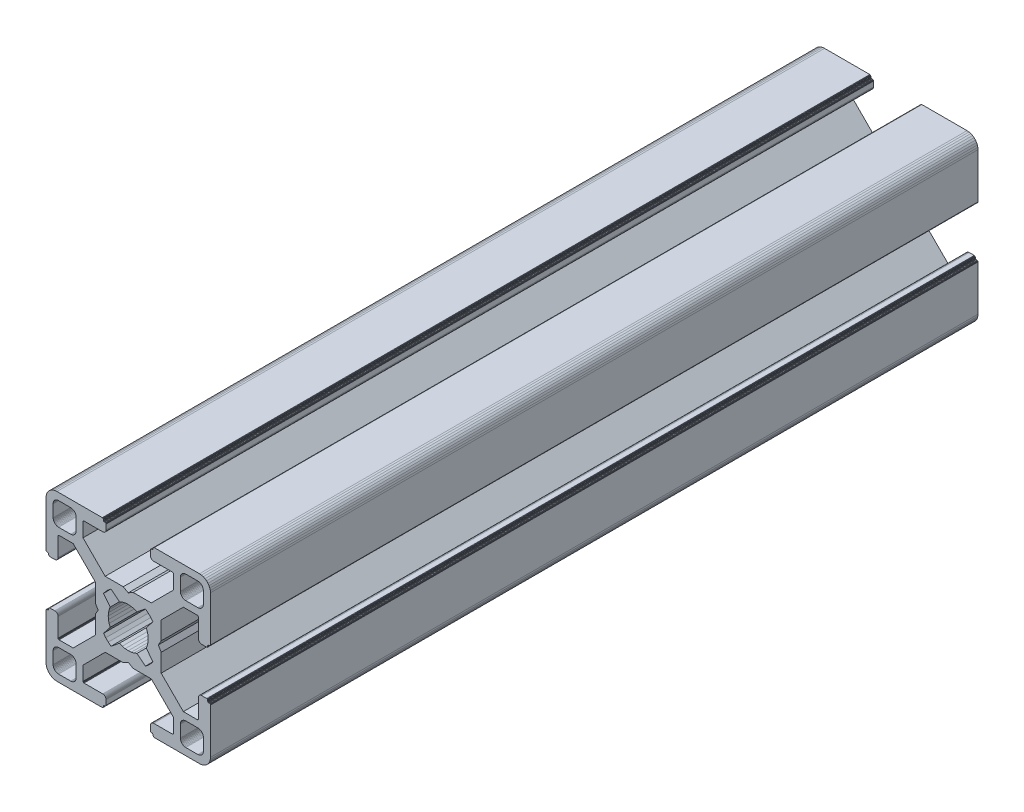
from build123d import *

# Parameters (mm, degrees)
BOSS_EXTRUDE1_DEPTH = 140


with BuildPart() as part:
    # Sketch1 → Boss-Extrude1 (new body)
    with BuildSketch(Plane.XY):
        Polygon((28.34729664, 29.969613999), (28.000000864, 29.999999329), (19.750000909, 29.999999329), (19.715268165, 29.996961355), (19.681595266, 29.987938702), (19.649999216, 29.973205179), (19.621443003, 29.953207821), (19.596790895, 29.928557575), (19.576793537, 29.899999499), (19.562061876, 29.868405312), (19.55303736, 29.834728688), (19.549999386, 29.799999669), (19.549999386, 29.699999839), (19.546961412, 29.665268958), (19.537936896, 29.631596059), (19.523203373, 29.599998146), (19.503207877, 29.571441934), (19.478557631, 29.546789825), (19.449999556, 29.526794329), (19.418403506, 29.512060806), (19.384728745, 29.503038153), (19.349999726, 29.500000179), (19.249999896, 29.500000179), (19.215267517, 29.496958527), (19.181592755, 29.487935874), (19.149996706, 29.47320235), (19.12143863, 29.453206855), (19.096788384, 29.428554746), (19.076791026, 29.399996671), (19.062057503, 29.368402484), (19.05303485, 29.334725859), (19.049996876, 29.299998703), (19.049996876, 28.39999837), (19.059110798, 28.29580945), (19.08618062, 28.194785165), (19.13038119, 28.099997016), (19.190369539, 28.014324653), (19.264324002, 27.94037019), (19.349996366, 27.88038184), (19.444784515, 27.836181271), (19.545806937, 27.809111449), (19.650010894, 27.799984574), (23.050010706, 27.799984574), (23.084741588, 27.7969466), (23.118414487, 27.787923946), (23.150012399, 27.773190423), (23.178568612, 27.753193065), (23.203220721, 27.728542819), (23.223218079, 27.699984744), (23.237949739, 27.668386831), (23.246974255, 27.634713932), (23.25001142, 27.59998608), (23.25001142, 25.049987618), (19.204474482, 20.999982084), (15.900007876, 20.999982084), (15.000008474, 20.48483404), (14.10000814, 20.999982084), (10.795543398, 20.999982084), (7.997342887, 23.801274731), (6.750011387, 25.049984589), (6.750011387, 27.599983051), (6.753049362, 27.634713932), (6.762072946, 27.668386831), (6.776805538, 27.699984744), (6.796801965, 27.728542819), (6.821454073, 27.753193065), (6.850011218, 27.773190423), (6.881607267, 27.787923946), (6.915282029, 27.7969466), (6.950011048, 27.799984574), (10.350011791, 27.799984574), (10.45420071, 27.809098497), (10.555223133, 27.836168318), (10.650011282, 27.880368888), (10.735683645, 27.940357238), (10.809638108, 28.014311701), (10.869626458, 28.099984064), (10.913827027, 28.194772213), (10.940895918, 28.295796498), (10.950010772, 28.399985417), (10.950010772, 29.299985751), (10.946974575, 29.334739239), (10.93795065, 29.368415522), (10.923215933, 29.400009153), (10.903218427, 29.428566473), (10.878566319, 29.45321765), (10.849999264, 29.473204166), (10.818403214, 29.487937689), (10.784728453, 29.496960342), (10.749999434, 29.500000179), (10.649999604, 29.500000179), (10.615270585, 29.503038153), (10.581595823, 29.512060806), (10.549999774, 29.526794329), (10.521441698, 29.546789825), (10.496791452, 29.571441934), (10.476795025, 29.599998146), (10.462061502, 29.631596059), (10.453037918, 29.665268958), (10.449999943, 29.699999839), (10.449999943, 29.799999669), (10.446961969, 29.834728688), (10.437938385, 29.868405312), (10.423205793, 29.899999499), (10.403208435, 29.928557575), (10.378557257, 29.953207821), (10.350000113, 29.973205179), (10.318404064, 29.987938702), (10.284729302, 29.996961355), (10.250000283, 29.999999329), (1.999999397, 29.999999329), (1.652702689, 29.969613999), (1.315958682, 29.879383743), (0.999999233, 29.732050374), (0.714424066, 29.532089829), (0.467910431, 29.285576195), (0.267948955, 28.999999166), (0.120614655, 28.684040532), (0.030384399, 28.34729664), (0, 28.000000864), (0, 19.750000909), (0.003037974, 19.715268165), (0.012061559, 19.681595266), (0.026795082, 19.649999216), (0.046790577, 19.621441141), (0.071442686, 19.596789032), (0.09999983, 19.576793537), (0.13159588, 19.562060013), (0.165270641, 19.55303736), (0.19999966, 19.549999386), (0.299999461, 19.549999386), (0.334728509, 19.546959549), (0.368403242, 19.537936896), (0.399999321, 19.523203373), (0.428556465, 19.503207877), (0.453208573, 19.478555769), (0.473204069, 19.449997693), (0.487937592, 19.418403506), (0.496961176, 19.384728745), (0.499999151, 19.349999726), (0.499999151, 19.249998033), (0.503038056, 19.215269014), (0.512060709, 19.181594253), (0.526794232, 19.150000066), (0.546790194, 19.121441524), (0.571441837, 19.096789882), (0.60000029, 19.076794925), (0.631595686, 19.062061999), (0.665270619, 19.053039982), (0.700000626, 19.050000801), (1.60000096, 19.050000801), (1.704189879, 19.059116587), (1.805213233, 19.086186409), (1.90000045, 19.130385115), (1.985673745, 19.190375328), (2.059627277, 19.264327928), (2.119616325, 19.350002154), (2.163816196, 19.444788441), (2.190886018, 19.545812726), (2.200000872, 19.650001645), (2.200000872, 23.050001457), (2.203039777, 23.084732338), (2.212062431, 23.118405237), (2.226795954, 23.15000315), (2.246792381, 23.178559362), (2.271443558, 23.203211471), (2.300000702, 23.223206967), (2.331596752, 23.23794049), (2.365271513, 23.246965006), (2.400001464, 23.250001117), (4.950000857, 23.250001117), (7.997332093, 20.202670812), (8.995535423, 19.204467788), (8.995535423, 15.900001182), (9.515148227, 15.00000178), (8.995535423, 14.100002378), (8.995535423, 10.795536704), (4.950000857, 6.750002138), (2.400001464, 6.750002138), (2.365271513, 6.753040112), (2.331596752, 6.762063697), (2.300000702, 6.77679722), (2.271443558, 6.796793647), (2.246792381, 6.821444824), (2.226795954, 6.850001968), (2.212062431, 6.881598018), (2.203039777, 6.915272779), (2.200000872, 6.950002729), (2.200000872, 10.350002542), (2.190896812, 10.454174265), (2.16382699, 10.555197618), (2.119627119, 10.649984836), (2.059638071, 10.735658131), (1.985684539, 10.809611663), (1.900011244, 10.869600944), (1.805224027, 10.913800582), (1.704200673, 10.940870404), (1.600011754, 10.949986189), (0.70001142, 10.949986189), (0.665281355, 10.946948596), (0.631606253, 10.937926283), (0.600010578, 10.923193954), (0.571451747, 10.903199537), (0.546799638, 10.87854836), (0.526794232, 10.850000195), (0.512060709, 10.818404146), (0.503038056, 10.784730315), (0.499999151, 10.750000365), (0.499999151, 10.650000535), (0.496961176, 10.615270585), (0.487937592, 10.581596754), (0.473204069, 10.550000705), (0.453208573, 10.521443561), (0.428556465, 10.496791452), (0.399999321, 10.476795956), (0.368403242, 10.462062433), (0.334728509, 10.453038849), (0.299999461, 10.449999943), (0.19999966, 10.449999943), (0.165270641, 10.446961969), (0.13159588, 10.437939316), (0.09999983, 10.423205793), (0.071442686, 10.403209366), (0.046790577, 10.378558189), (0.026795082, 10.350000113), (0.012061559, 10.318404064), (0.003037974, 10.284729302), (0, 10.250000283), (0, 1.999999397), (0.030384399, 1.652702689), (0.120614655, 1.315958682), (0.267948955, 0.999999233), (0.467910431, 0.714424066), (0.714424066, 0.467910431), (0.999999233, 0.267948955), (1.315958682, 0.120614655), (1.652702689, 0.030384399), (1.999999397, 0), (10.250000283, 0), (10.284729302, 0.003037974), (10.318404064, 0.012061559), (10.350000113, 0.026795082), (10.378557257, 0.046790577), (10.403208435, 0.071442686), (10.423205793, 0.09999983), (10.437938385, 0.13159588), (10.446961969, 0.165270641), (10.449999943, 0.19999966), (10.449999943, 0.300000422), (10.453037918, 0.334729441), (10.462061502, 0.368404202), (10.476795025, 0.400000252), (10.496791452, 0.428557396), (10.521441698, 0.453208573), (10.549999774, 0.473205), (10.581595823, 0.487938523), (10.615270585, 0.496961176), (10.649999604, 0.500000082), (10.749999434, 0.500000082), (10.784728453, 0.503038056), (10.818403214, 0.512060709), (10.849999264, 0.526794232), (10.878547894, 0.546800104), (10.903198606, 0.571451747), (10.923194493, 0.6000102), (10.93792742, 0.631606528), (10.946949437, 0.66528146), (10.950010772, 0.699984975), (10.950010772, 1.599985308), (10.940895918, 1.704174228), (10.913827027, 1.805197581), (10.869626458, 1.89998573), (10.809638108, 1.985658094), (10.735683645, 2.059612557), (10.650011282, 2.119600674), (10.555223133, 2.163801476), (10.45420071, 2.190870367), (10.350011791, 2.199985221), (6.950011048, 2.199985221), (6.915282029, 2.203024126), (6.881607267, 2.212046779), (6.850011218, 2.226780302), (6.821454073, 2.246776729), (6.796801965, 2.271427907), (6.776805538, 2.299985982), (6.762072946, 2.331582032), (6.753049362, 2.365256793), (6.750011387, 2.399985812), (6.750011387, 4.949985206), (9.787457566, 7.990785077), (10.795545277, 8.999985833), (14.100010019, 8.999985833), (15.000010353, 9.515133877), (15.900009756, 8.999985833), (19.204476361, 8.999985833), (20.21256413, 7.990786065), (23.25001142, 4.949988235), (23.25001142, 2.399988841), (23.246974255, 2.365256793), (23.237949739, 2.331582032), (23.223218079, 2.299985982), (23.203220721, 2.271427907), (23.178568612, 2.246776729), (23.150012399, 2.226780302), (23.118414487, 2.212046779), (23.084741588, 2.203024126), (23.050010706, 2.199985221), (19.650010894, 2.199985221), (19.545806937, 2.190883319), (19.444784515, 2.163814428), (19.349996366, 2.119613626), (19.264324002, 2.059625509), (19.190369539, 1.985671046), (19.13038119, 1.899998682), (19.08618062, 1.805210533), (19.059110798, 1.70418718), (19.049996876, 1.599998261), (19.049996876, 0.699997927), (19.053035506, 0.665268966), (19.062058795, 0.631594374), (19.076792915, 0.599998603), (19.096790813, 0.571440905), (19.121441524, 0.546790194), (19.149999978, 0.526794306), (19.181596306, 0.51206138), (19.215271238, 0.503039363), (19.249999896, 0.500000082), (19.349999726, 0.500000082), (19.384728745, 0.496961176), (19.418403506, 0.487938523), (19.449999556, 0.473205), (19.478557631, 0.453208573), (19.503207877, 0.428557396), (19.523203373, 0.400000252), (19.537936896, 0.368404202), (19.546961412, 0.334729441), (19.549999386, 0.300000422), (19.549999386, 0.19999966), (19.55303736, 0.165270641), (19.562061876, 0.13159588), (19.576793537, 0.09999983), (19.596789964, 0.071441755), (19.621442072, 0.046789646), (19.649998285, 0.02679415), (19.681594335, 0.012060627), (19.715267234, 0.003037043), (19.750000909, 0), (28.000000864, 0), (28.34729664, 0.030384399), (28.684040532, 0.120614655), (28.999999166, 0.267948955), (29.285576195, 0.467910431), (29.532089829, 0.714424066), (29.732050374, 0.999999233), (29.879383743, 1.315958682), (29.969613999, 1.652702689), (29.999999329, 1.999999397), (29.999999329, 10.250000283), (29.996974806, 10.284715361), (29.987951516, 10.318389952), (29.973217396, 10.349985723), (29.953219499, 10.378543421), (29.928568787, 10.403194133), (29.899999499, 10.423205793), (29.868405312, 10.437939316), (29.834728688, 10.446961969), (29.799999669, 10.449999943), (29.699999839, 10.449999943), (29.664909937, 10.453400043), (29.631233313, 10.462423628), (29.599637263, 10.477157151), (29.57108105, 10.497152646), (29.546427079, 10.521804755), (29.526433446, 10.550361899), (29.511699923, 10.581957949), (29.502675407, 10.615631779), (29.499637433, 10.650361729), (29.499637433, 10.750361559), (29.49697202, 10.784715548), (29.487949367, 10.818389378), (29.473215844, 10.849985428), (29.453220348, 10.878542572), (29.428568239, 10.90319468), (29.400010164, 10.923190176), (29.368415977, 10.937923699), (29.334741215, 10.946947284), (29.300012197, 10.949986189), (28.400011863, 10.949986189), (28.29581215, 10.9408876), (28.194787865, 10.913817778), (28.099999716, 10.86961814), (28.014327352, 10.809628859), (27.940374752, 10.735675327), (27.880384539, 10.650002032), (27.836185833, 10.555214814), (27.809114148, 10.454191461), (27.800000225, 10.350002542), (27.800000225, 6.950002729), (27.796962251, 6.915272779), (27.787939598, 6.881598018), (27.773206075, 6.850001968), (27.753208716, 6.821444824), (27.728558471, 6.796793647), (27.700000395, 6.77679722), (27.668404345, 6.762063697), (27.634729584, 6.753040112), (27.599998702, 6.750002138), (25.05000024, 6.750002138), (23.809199132, 7.99080223), (21.004464477, 10.795534588), (21.004464477, 14.100000262), (20.484851673, 14.999999665), (21.004464477, 15.899999067), (21.004464477, 19.204465672), (25.05000024, 23.250001117), (27.599998702, 23.250001117), (27.634729584, 23.246965006), (27.668404345, 23.23794049), (27.700000395, 23.223206967), (27.728558471, 23.203211471), (27.753208716, 23.178559362), (27.773206075, 23.15000315), (27.787939598, 23.118405237), (27.796962251, 23.084732338), (27.800000225, 23.050001457), (27.800000225, 19.650001645), (27.809114148, 19.545812726), (27.836185833, 19.444788441), (27.880384539, 19.350002154), (27.940370508, 19.264323684), (28.014323108, 19.190371084), (28.099995472, 19.130380872), (28.194783621, 19.086182165), (28.295807906, 19.059112343), (28.400001069, 19.050000801), (29.300001402, 19.050000801), (29.334730421, 19.053040638), (29.368405183, 19.062063291), (29.39999937, 19.076796814), (29.42819671, 19.097149726), (29.452848353, 19.1218023), (29.472843309, 19.150360754), (29.487576235, 19.181955219), (29.496598252, 19.215630151), (29.499637433, 19.250359227), (29.499637433, 19.35036092), (29.502675407, 19.385089939), (29.511699923, 19.4187647), (29.526433446, 19.450358887), (29.546427079, 19.478916963), (29.57108105, 19.503569071), (29.599637263, 19.523564567), (29.631233313, 19.53829809), (29.664909937, 19.547320743), (29.699999839, 19.549999386), (29.799999669, 19.549999386), (29.834728688, 19.55303736), (29.868405312, 19.562060013), (29.899999499, 19.576793537), (29.928557575, 19.596789032), (29.953207821, 19.621441141), (29.973205179, 19.649999216), (29.987938702, 19.681595266), (29.996961355, 19.715268165), (29.999999329, 19.750000909), (29.999999329, 28.000000864), (29.969613999, 28.34729664), (29.879383743, 28.684040532), (29.732050374, 28.999999166), (29.532089829, 29.285576195), (29.285576195, 29.532089829), (28.999999166, 29.732050374), (28.684040532, 29.879383743), align=None)
        Polygon((1.299998723, 25.499999523), (1.299998723, 27.699999511), (1.312309876, 27.856435627), (1.348942518, 28.009016067), (1.408992335, 28.153989464), (1.490981318, 28.287785128), (1.592892222, 28.407108039), (1.71221327, 28.50901708), (1.846008119, 28.591006994), (1.9909814, 28.651056811), (2.143563703, 28.687689453), (2.299998887, 28.699999675), (4.499998875, 28.699999675), (4.656434059, 28.687689453), (4.809016362, 28.651056811), (4.953989759, 28.591006994), (5.087784491, 28.50901708), (5.207106471, 28.407108039), (5.309016444, 28.287785128), (5.391005427, 28.153989464), (5.451056175, 28.009016067), (5.487687886, 27.856435627), (5.499999039, 27.699999511), (5.499999039, 25.499999523), (5.487687886, 25.34356527), (5.451056175, 25.190982968), (5.391005427, 25.04600957), (5.309016444, 24.912213907), (5.207106471, 24.792892858), (5.087784491, 24.690981954), (4.953989759, 24.60899204), (4.809016362, 24.548944086), (4.656434059, 24.512309581), (4.499998875, 24.499999359), (2.299998887, 24.499999359), (2.143563703, 24.512309581), (1.9909814, 24.548944086), (1.846008119, 24.60899204), (1.71221327, 24.690981954), (1.592892222, 24.792892858), (1.490981318, 24.912213907), (1.408992335, 25.04600957), (1.348942518, 25.190982968), (1.312309876, 25.34356527), align=None, mode=Mode.SUBTRACT)
        Polygon((25.34356527, 28.687689453), (25.499999523, 28.699999675), (27.699999511, 28.699999675), (27.856435627, 28.687689453), (28.009017929, 28.651056811), (28.153991327, 28.591006994), (28.28778699, 28.50901708), (28.407108039, 28.407108039), (28.50901708, 28.287785128), (28.591006994, 28.153989464), (28.651056811, 28.009016067), (28.687689453, 27.856435627), (28.700001538, 27.699999511), (28.700001538, 25.499999523), (28.687689453, 25.34356527), (28.651056811, 25.190982968), (28.591006994, 25.04600957), (28.50901708, 24.912213907), (28.407108039, 24.792892858), (28.28778699, 24.690981954), (28.153991327, 24.60899204), (28.009017929, 24.548944086), (27.856435627, 24.512309581), (27.699999511, 24.499999359), (25.499999523, 24.499999359), (25.34356527, 24.512309581), (25.190982968, 24.548944086), (25.04600957, 24.60899204), (24.912215769, 24.690981954), (24.792892858, 24.792892858), (24.690981954, 24.912213907), (24.608993903, 25.04600957), (24.548944086, 25.190982968), (24.512311444, 25.34356527), (24.500001222, 25.499999523), (24.500001222, 27.699999511), (24.512311444, 27.856435627), (24.548944086, 28.009016067), (24.608993903, 28.153989464), (24.690981954, 28.287785128), (24.792892858, 28.407108039), (24.912215769, 28.50901708), (25.04600957, 28.591006994), (25.190982968, 28.651056811), align=None, mode=Mode.SUBTRACT)
        Polygon((14.999999665, 18.649999052), (15.550030395, 18.608318642), (16.087498516, 18.484227359), (16.600128263, 18.280562013), (18.13592948, 19.518401474), (18.644984812, 19.11874488), (19.103571773, 18.662061542), (19.505336881, 18.154669553), (18.280562013, 16.600130126), (18.484227359, 16.087498516), (18.608318642, 15.550030395), (18.649999052, 14.999999665), (18.608318642, 14.449968934), (18.484227359, 13.912500814), (18.280562013, 13.399870135), (19.505336881, 11.845329776), (19.103571773, 11.337937787), (18.644984812, 10.881252587), (18.13592948, 10.481598787), (16.600128263, 11.719437316), (16.087498516, 11.515771039), (15.550030395, 11.391680688), (14.999999665, 11.349999346), (14.449968934, 11.391680688), (13.912500814, 11.515771039), (13.399870135, 11.719437316), (11.864069849, 10.481598787), (11.355013587, 10.881252587), (10.896427557, 11.337937787), (10.494662449, 11.845329776), (11.719438247, 13.399870135), (11.515771039, 13.912500814), (11.391680688, 14.449968934), (11.349999346, 14.999999665), (11.391680688, 15.550030395), (11.515771039, 16.087498516), (11.719438247, 16.600130126), (10.494662449, 18.154669553), (10.896427557, 18.662061542), (11.355013587, 19.11874488), (11.864069849, 19.518401474), (13.399870135, 18.280562013), (13.912500814, 18.484227359), (14.449968934, 18.608318642), align=None, mode=Mode.SUBTRACT)
        Polygon((4.499998875, 1.299999771), (2.299998887, 1.299999771), (2.143563703, 1.312310807), (1.9909814, 1.348942518), (1.846008119, 1.408992335), (1.71221327, 1.490982249), (1.592892222, 1.592892222), (1.490981318, 1.712214202), (1.408992335, 1.846008934), (1.348942518, 1.990982331), (1.312309876, 2.143564634), (1.299998723, 2.299998887), (1.299998723, 4.499999806), (1.312309876, 4.656434059), (1.348942518, 4.809017293), (1.408992335, 4.95399069), (1.490981318, 5.087785423), (1.592892222, 5.207106471), (1.71221327, 5.309017375), (1.846008119, 5.391006358), (1.9909814, 5.451056175), (2.143563703, 5.487688817), (2.299998887, 5.49999997), (4.499998875, 5.49999997), (4.656434059, 5.487688817), (4.809016362, 5.451056175), (4.953989759, 5.391006358), (5.087784491, 5.309017375), (5.207106471, 5.207106471), (5.309016444, 5.087785423), (5.391005427, 4.95399069), (5.451056175, 4.809017293), (5.487687886, 4.656434059), (5.499999039, 4.499999806), (5.499999039, 2.299998887), (5.487687886, 2.143564634), (5.451056175, 1.990982331), (5.391005427, 1.846008934), (5.309016444, 1.712214202), (5.207106471, 1.592892222), (5.087784491, 1.490982249), (4.953989759, 1.408992335), (4.809016362, 1.348942518), (4.656434059, 1.312310807), align=None, mode=Mode.SUBTRACT)
        Polygon((27.699999511, 1.299999771), (25.499999523, 1.299999771), (25.34356527, 1.312310807), (25.190982968, 1.348942518), (25.04600957, 1.408992335), (24.912215769, 1.490982249), (24.792892858, 1.592892222), (24.690981954, 1.712214202), (24.608993903, 1.846008934), (24.548944086, 1.990982331), (24.512311444, 2.143564634), (24.500001222, 2.299998887), (24.500001222, 4.499999806), (24.512311444, 4.656434059), (24.548944086, 4.809017293), (24.608993903, 4.95399069), (24.690981954, 5.087785423), (24.792892858, 5.207106471), (24.912215769, 5.309017375), (25.04600957, 5.391006358), (25.190982968, 5.451056175), (25.34356527, 5.487688817), (25.499999523, 5.49999997), (27.699999511, 5.49999997), (27.856435627, 5.487688817), (28.009017929, 5.451056175), (28.153991327, 5.391006358), (28.28778699, 5.309017375), (28.407108039, 5.207106471), (28.50901708, 5.087785423), (28.591006994, 4.95399069), (28.651056811, 4.809017293), (28.687689453, 4.656434059), (28.700001538, 4.499999806), (28.700001538, 2.299998887), (28.687689453, 2.143564634), (28.651056811, 1.990982331), (28.591006994, 1.846008934), (28.50901708, 1.712214202), (28.407108039, 1.592892222), (28.28778699, 1.490982249), (28.153991327, 1.408992335), (28.009017929, 1.348942518), (27.856435627, 1.312310807), align=None, mode=Mode.SUBTRACT)
    extrude(amount=-BOSS_EXTRUDE1_DEPTH)


solid = part.part
